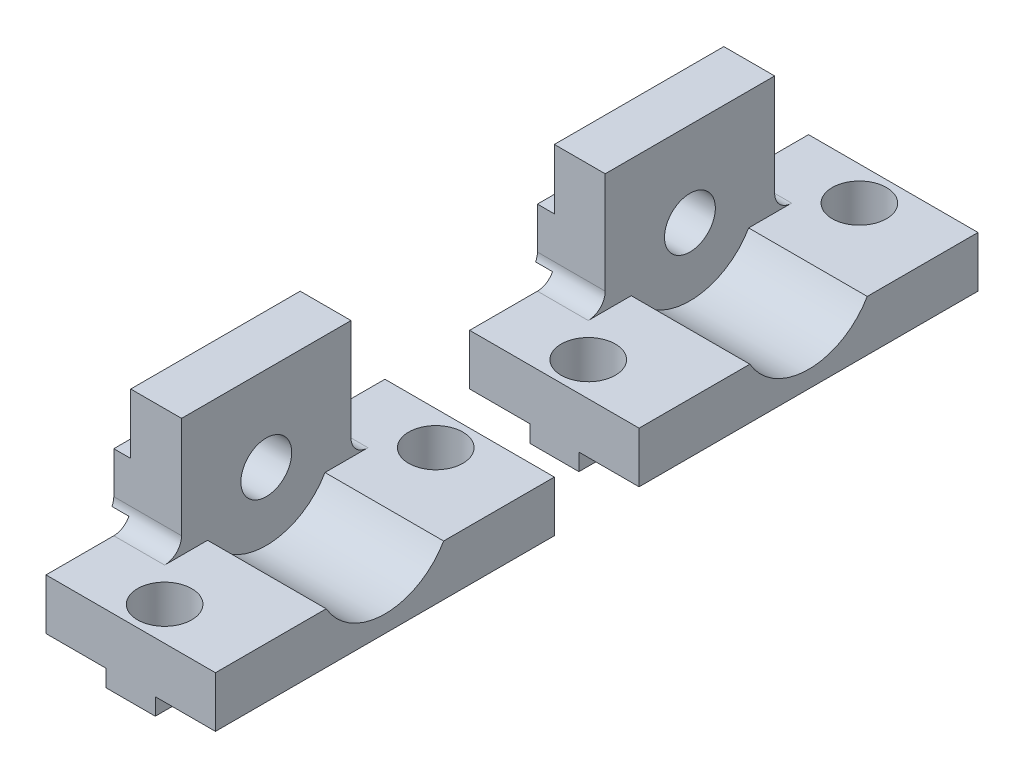
from build123d import *

# Parameters (mm, degrees)
MAIN_DEPTH                 = 20
ESQUISSE4_W                = 20
ESQUISSE4_H                = 2.9
VERTICAL_FIX_DEPTH         = 1
ESQUISSE2_R                = 1.5
VERTICAL_HOLE_DEPTH        = 25.494897428
VERTICAL_HOLE_DEPTH_BACK   = 25.494897428
ESQUISSE6_W                = 5
ESQUISSE6_H                = 7
CUT_BORDERS_DEPTH          = 24.430749028
ESQUISSE7_W                = 2.9
ESQUISSE7_H                = 1
BOSS_EXTRU_1_DEPTH         = 20
ESQUISSE3_R                = 1.6
HORIZONTAL_HOLE_DEPTH      = 24.430749028
HORIZONTAL_HOLE_DEPTH_BACK = 24.430749028
ESQUISSE8_R                = 4
ENL_V_MAT_EXTRU_4_DEPTH    = 24.430749028
CONG_1_R                   = 1
R_P_TITION_LIN_AIRE1_COUNT = 2
R_P_TITION_LIN_AIRE1_PITCH = 25


with BuildPart() as part:
    # Esquisse1 → Main (new body)
    with BuildSketch(Plane.XY):
        Polygon((0, 0), (10, 0), (10, 3), (3, 3), (3, 10), (0, 10), align=None)
    extrude(amount=MAIN_DEPTH)

    # Esquisse4 → Vertical Fix (add)
    with BuildSketch(Plane.ZY):
        with Locations((10, 5)):
            Rectangle(ESQUISSE4_W, ESQUISSE4_H)
    extrude(amount=VERTICAL_FIX_DEPTH)

    # Esquisse2 → Vertical Hole (cut, two sides)
    with BuildSketch(Plane.ZY) as vertical_hole_sk:
        with Locations(Location((10, 5, 0), (0, 0, 270))):
            Circle(ESQUISSE2_R)
    extrude(amount=VERTICAL_HOLE_DEPTH, mode=Mode.SUBTRACT)
    extrude(vertical_hole_sk.sketch, amount=-VERTICAL_HOLE_DEPTH_BACK, mode=Mode.SUBTRACT)

    # Esquisse6 → Cut Borders (cut, through all)
    with BuildSketch(Plane(origin=(3, 0, 0), x_dir=(0, 0, -1), z_dir=(1, 0, 0))):
        with Locations((-17.5, 6.5)):
            Rectangle(ESQUISSE6_W, ESQUISSE6_H)
        with Locations((-2.5, 6.5)):
            Rectangle(ESQUISSE6_W, ESQUISSE6_H)
    extrude(amount=-CUT_BORDERS_DEPTH, mode=Mode.SUBTRACT)

    # Esquisse7 → Boss.-Extru.1 (add)
    with BuildSketch(Plane.XY.offset(20)):
        with Locations((5, -0.5)):
            Rectangle(ESQUISSE7_W, ESQUISSE7_H)
    extrude(amount=-BOSS_EXTRU_1_DEPTH)

    # Esquisse3 → Horizontal Hole (cut, two sides)
    with BuildSketch(Plane.XZ.offset(-3)) as horizontal_hole_sk:
        with Locations((5, 2)):
            Circle(ESQUISSE3_R)
        with Locations((5, 18)):
            Circle(ESQUISSE3_R)
    extrude(amount=HORIZONTAL_HOLE_DEPTH, mode=Mode.SUBTRACT)
    extrude(horizontal_hole_sk.sketch, amount=-HORIZONTAL_HOLE_DEPTH_BACK, mode=Mode.SUBTRACT)

    # Esquisse8 → Enlèv. mat.-Extru.4 (cut, through all)
    with BuildSketch(Plane(origin=(3, 0, 0), x_dir=(0, 0, -1), z_dir=(1, 0, 0))):
        with Locations((-10, 5)):
            Circle(ESQUISSE8_R)
    extrude(amount=ENL_V_MAT_EXTRU_4_DEPTH, mode=Mode.SUBTRACT)

    # Congé1
    cong_1_edges = [part.edges().sort_by_distance(p)[0] for p in [
        (1.5, 3, 15),
        (1.5, 3, 5),
    ]]
    fillet(cong_1_edges, radius=CONG_1_R)


with BuildPart() as r_p_tition_lin_aire1_1:
    # Répétition linéaire1: pattern copy
    add(part.part.moved(Location(Vector(0, 0, -1) * (1 * R_P_TITION_LIN_AIRE1_PITCH))))


solid = Compound([part.part, r_p_tition_lin_aire1_1.part])
